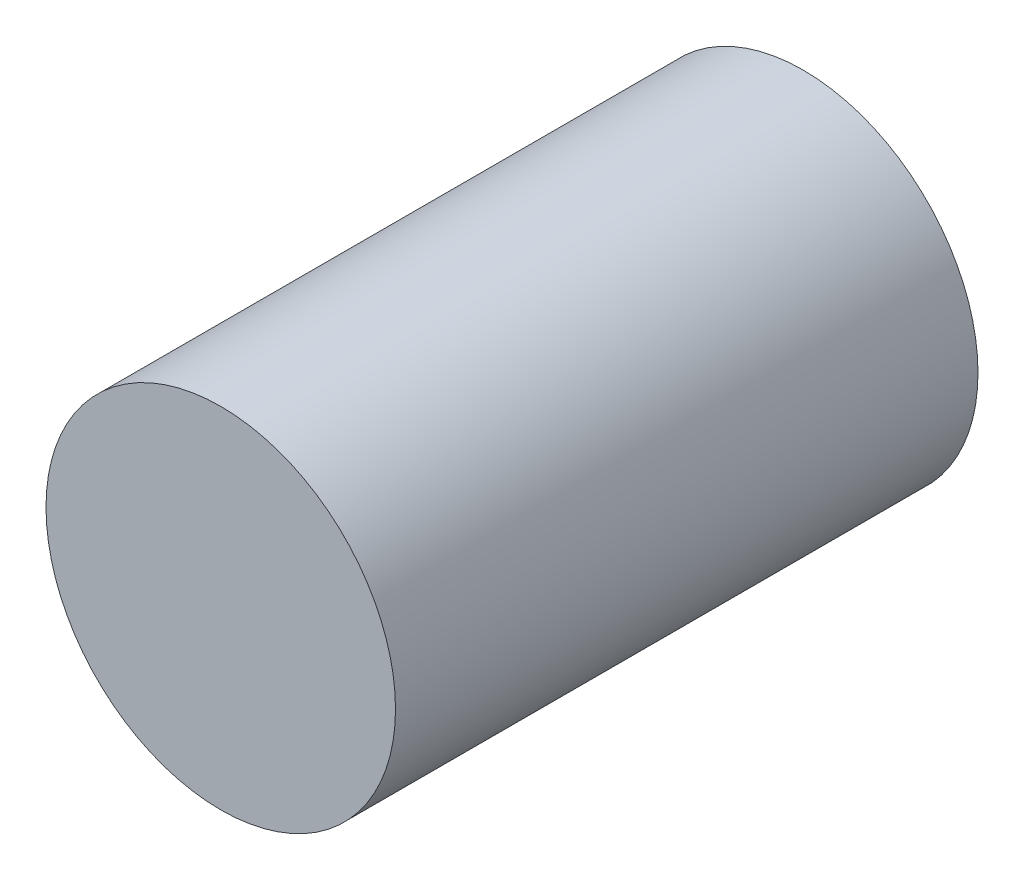
from build123d import *

# Parameters (mm, degrees)
SKETCH1_R           = 13.5
BOSS_EXTRUDE1_DEPTH = 45


with BuildPart() as part:
    # Sketch1 → Boss-Extrude1 (new body)
    with BuildSketch(Plane.XY):
        Circle(SKETCH1_R)
    extrude(amount=BOSS_EXTRUDE1_DEPTH)


solid = part.part
